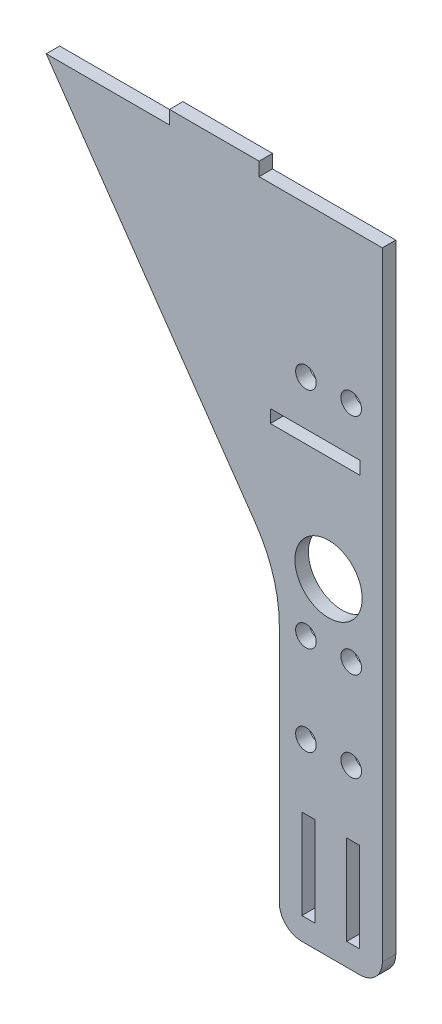
from build123d import *

# Parameters (mm, degrees)
SKETCH1_W           = 2.9
SKETCH1_H           = 20
BOSS_EXTRUDE1_DEPTH = 3
FILLET1_R           = 5
FILLET2_R           = 30
CUT_EXTRUDE1_REACH  = 5
SKETCH3_R           = 7.5
SKETCH3_R_2         = 2.3
SKETCH5_W           = 20
SKETCH5_H           = 2.9
CUT_EXTRUDE2_DEPTH  = 3
SKETCH6_R           = 2.3
CUT_EXTRUDE3_DEPTH  = 3


with BuildPart() as part:
    # Sketch1 → Boss-Extrude1 (new body)
    with BuildSketch(Plane.XY):
        Polygon((0, 0), (-23, 0), (-23, 68), (-75, 143), (-47.5, 143), (-47.5, 146), (-27.5, 146), (-27.5, 143), (0, 143), align=None)
        with Locations((-16.5, 15)):
            Rectangle(SKETCH1_W, SKETCH1_H, mode=Mode.SUBTRACT)
        with Locations((-6.5, 15)):
            Rectangle(SKETCH1_W, SKETCH1_H, mode=Mode.SUBTRACT)
    extrude(amount=BOSS_EXTRUDE1_DEPTH)

    # Fillet1
    fillet1_edges = [part.edges().sort_by_distance(p)[0] for p in [
        (0, 0, 1.5),
        (-23, 0, 1.5),
    ]]
    fillet(fillet1_edges, radius=FILLET1_R)

    # Fillet2
    fillet2_edges = [part.edges().sort_by_distance(p)[0] for p in [
        (-23, 68, 1.5),
    ]]
    fillet(fillet2_edges, radius=FILLET2_R)

    # Sketch3 → Cut-Extrude1 (cut, up to next)
    with BuildSketch(Plane(origin=(0, 0, 0), x_dir=(-1, 0, 0), z_dir=(0, 0, -1)), mode=Mode.PRIVATE) as cut_extrude1_sk1:
        with Locations((12, 73)):
            Circle(SKETCH3_R)
    cut_extrude1_tool1 = extrude(cut_extrude1_sk1.sketch, amount=-CUT_EXTRUDE1_REACH, mode=Mode.PRIVATE) & part.part
    add(cut_extrude1_tool1.solids().sort_by_distance((-12, 73, 0))[0], mode=Mode.SUBTRACT)
    # Sketch3 → Cut-Extrude1 (cut, up to next)
    with BuildSketch(Plane(origin=(0, 0, 0), x_dir=(-1, 0, 0), z_dir=(0, 0, -1)), mode=Mode.PRIVATE) as cut_extrude1_sk2:
        with Locations((17.05, 59.5)):
            Circle(SKETCH3_R_2)
    cut_extrude1_tool2 = extrude(cut_extrude1_sk2.sketch, amount=-CUT_EXTRUDE1_REACH, mode=Mode.PRIVATE) & part.part
    add(cut_extrude1_tool2.solids().sort_by_distance((-17.05, 59.5, 0))[0], mode=Mode.SUBTRACT)
    # Sketch3 → Cut-Extrude1 (cut, up to next)
    with BuildSketch(Plane(origin=(0, 0, 0), x_dir=(-1, 0, 0), z_dir=(0, 0, -1)), mode=Mode.PRIVATE) as cut_extrude1_sk3:
        with Locations((6.95, 59.5)):
            Circle(SKETCH3_R_2)
    cut_extrude1_tool3 = extrude(cut_extrude1_sk3.sketch, amount=-CUT_EXTRUDE1_REACH, mode=Mode.PRIVATE) & part.part
    add(cut_extrude1_tool3.solids().sort_by_distance((-6.95, 59.5, 0))[0], mode=Mode.SUBTRACT)
    # Sketch3 → Cut-Extrude1 (cut, up to next)
    with BuildSketch(Plane(origin=(0, 0, 0), x_dir=(-1, 0, 0), z_dir=(0, 0, -1)), mode=Mode.PRIVATE) as cut_extrude1_sk4:
        with Locations((17.05, 109.5)):
            Circle(SKETCH3_R_2)
    cut_extrude1_tool4 = extrude(cut_extrude1_sk4.sketch, amount=-CUT_EXTRUDE1_REACH, mode=Mode.PRIVATE) & part.part
    add(cut_extrude1_tool4.solids().sort_by_distance((-17.05, 109.5, 0))[0], mode=Mode.SUBTRACT)
    # Sketch3 → Cut-Extrude1 (cut, up to next)
    with BuildSketch(Plane(origin=(0, 0, 0), x_dir=(-1, 0, 0), z_dir=(0, 0, -1)), mode=Mode.PRIVATE) as cut_extrude1_sk5:
        with Locations((6.95, 109.5)):
            Circle(SKETCH3_R_2)
    cut_extrude1_tool5 = extrude(cut_extrude1_sk5.sketch, amount=-CUT_EXTRUDE1_REACH, mode=Mode.PRIVATE) & part.part
    add(cut_extrude1_tool5.solids().sort_by_distance((-6.95, 109.5, 0))[0], mode=Mode.SUBTRACT)

    # Sketch5 → Cut-Extrude2 (cut)
    with BuildSketch(Plane(origin=(0, 0, 0), x_dir=(-1, 0, 0), z_dir=(0, 0, -1))):
        with Locations((15, 98)):
            Rectangle(SKETCH5_W, SKETCH5_H)
    extrude(amount=-CUT_EXTRUDE2_DEPTH, mode=Mode.SUBTRACT)

    # Sketch6 → Cut-Extrude3 (cut)
    with BuildSketch(Plane.XY.offset(3)):
        with Locations((-17.05, 39.5)):
            Circle(SKETCH6_R)
        with Locations((-6.95, 39.5)):
            Circle(SKETCH6_R)
    extrude(amount=-CUT_EXTRUDE3_DEPTH, mode=Mode.SUBTRACT)


solid = part.part
